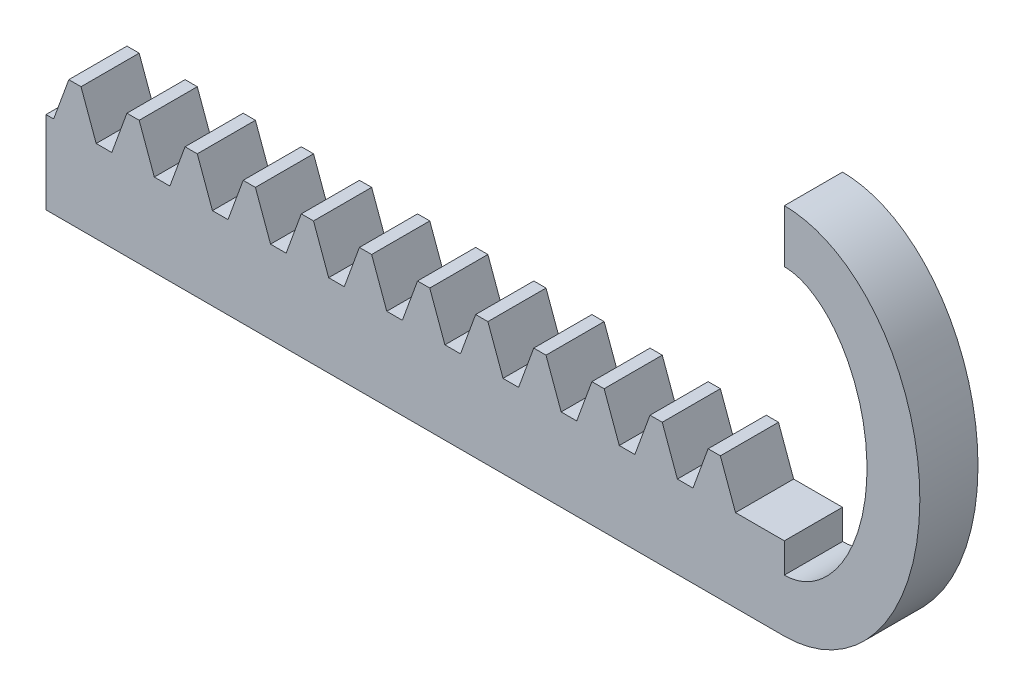
from build123d import *

# Parameters (mm, degrees)
BLANKSKE_W          = 100
BLANKSKE_H          = 11.75
BLANK_DEPTH         = 10
TOOTHCUTSIM_DEPTH   = 102.183311371
TEETHCUTS_COUNT     = 19
TEETHCUTS_PITCH     = 5.497787137
SKETCH_3_W          = 2.841503757
SKETCH_3_H          = 7.8125
EXTRUDE_1_DEPTH     = 10
EXTRUDE_2_DEPTH     = 5.5
SKETCH_6_W          = 102.841503757
SKETCH_6_H          = 15
CUT_EXTRUDE_2_DEPTH = 4.5
SKETCH_7_W          = 1.160244479
SKETCH_7_H          = 1.204796587
CUT_EXTRUDE_3_DEPTH = 5.5
SKETCH_8_W          = 16.666168626
SKETCH_8_H          = 26.64996686
CUT_EXTRUDE_5_DEPTH = 33


with BuildPart() as part:
    # BlankSke → Blank (new body)
    with BuildSketch(Plane.XY):
        with Locations((50, 5.875)):
            Rectangle(BLANKSKE_W, BLANKSKE_H)
    extrude(amount=-BLANK_DEPTH)

    # TooCutSkeSim → ToothCutSim (cut, through all)
    with BuildSketch(Plane.XY):
        Polygon((0.737261897, 7.8125), (-0.737261897, 7.8125), (-2.179639538, 11.7754), (2.179639538, 11.7754), align=None)
    toothcutsim = extrude(amount=-TOOTHCUTSIM_DEPTH, mode=Mode.SUBTRACT)

    # TeethCuts: ToothCutSim ×19
    with Locations(*[(i * TEETHCUTS_PITCH, 0, 0) for i in range(1, TEETHCUTS_COUNT)]):
        add(toothcutsim, mode=Mode.SUBTRACT)

    # 草图3 → 凸台-拉伸1 (add)
    with BuildSketch(Plane.XY):
        with Locations((101.420751878, 3.90625)):
            Rectangle(SKETCH_3_W, SKETCH_3_H)
    extrude(amount=-EXTRUDE_1_DEPTH)

    # 草图5 → 凸台-拉伸2 (add)
    with BuildSketch(Plane.XY):
        with BuildLine():
            Line((102.841503757, 0), (102.841503757, 5))
            add(Edge.make_bspline(
                [(102.841503757, 5), (103.239034049, 5), (104.005784609, 5.102799889), (105.677797401, 5.778606013), (107.956900824, 7.77823047), (110.125468295, 12.137732801), (110.929574998, 17.633214309), (110.125468295, 23.128695817), (107.956900824, 27.488198148), (105.677797401, 29.487822605), (104.005784609, 30.163628729), (103.239034049, 30.266428618), (102.841503757, 30.266428618)],
                knots=[3.141592654, 3.141592654, 3.141592654, 3.141592654, 3.337942194, 3.534291735, 3.926990817, 4.319689899, 4.71238898, 5.105088062, 5.497787144, 5.890486225, 6.086835766, 6.283185307, 6.283185307, 6.283185307, 6.283185307], degree=3))
            Line((102.841503757, 30.266428618), (102.841503757, 35.266428618))
            add(Edge.make_bspline(
                [(102.841503757, 0), (115.66153943, 0), (115.66153943, 17.633214309), (115.66153943, 35.266428618), (102.841503757, 35.266428618)],
                knots=[3.141592654, 3.141592654, 3.141592654, 4.71238898, 4.71238898, 6.283185307, 6.283185307, 6.283185307], degree=2, weights=[1, 0.707106781, 1, 0.707106781, 1]))
        make_face()
    extrude(amount=-EXTRUDE_2_DEPTH)

    # 草图6 → 切除-拉伸2 (cut)
    with BuildSketch(Plane(origin=(0, 0, -10), x_dir=(-1, 0, 0), z_dir=(0, 0, -1))):
        with Locations((-51.420751879, 7.5)):
            Rectangle(SKETCH_6_W, SKETCH_6_H)
    extrude(amount=-CUT_EXTRUDE_2_DEPTH, mode=Mode.SUBTRACT)

    # 草图7 → 切除-拉伸3 (cut)
    with BuildSketch(Plane.XY):
        with Locations((99.931909363, 8.414898294)):
            Rectangle(SKETCH_7_W, SKETCH_7_H)
    extrude(amount=-CUT_EXTRUDE_3_DEPTH, mode=Mode.SUBTRACT)

    # 草图8 → 切除-拉伸5 (cut)
    with BuildSketch(Plane.ZY):
        Rectangle(SKETCH_8_W, SKETCH_8_H)
    extrude(amount=-CUT_EXTRUDE_5_DEPTH, mode=Mode.SUBTRACT)


solid = part.part
